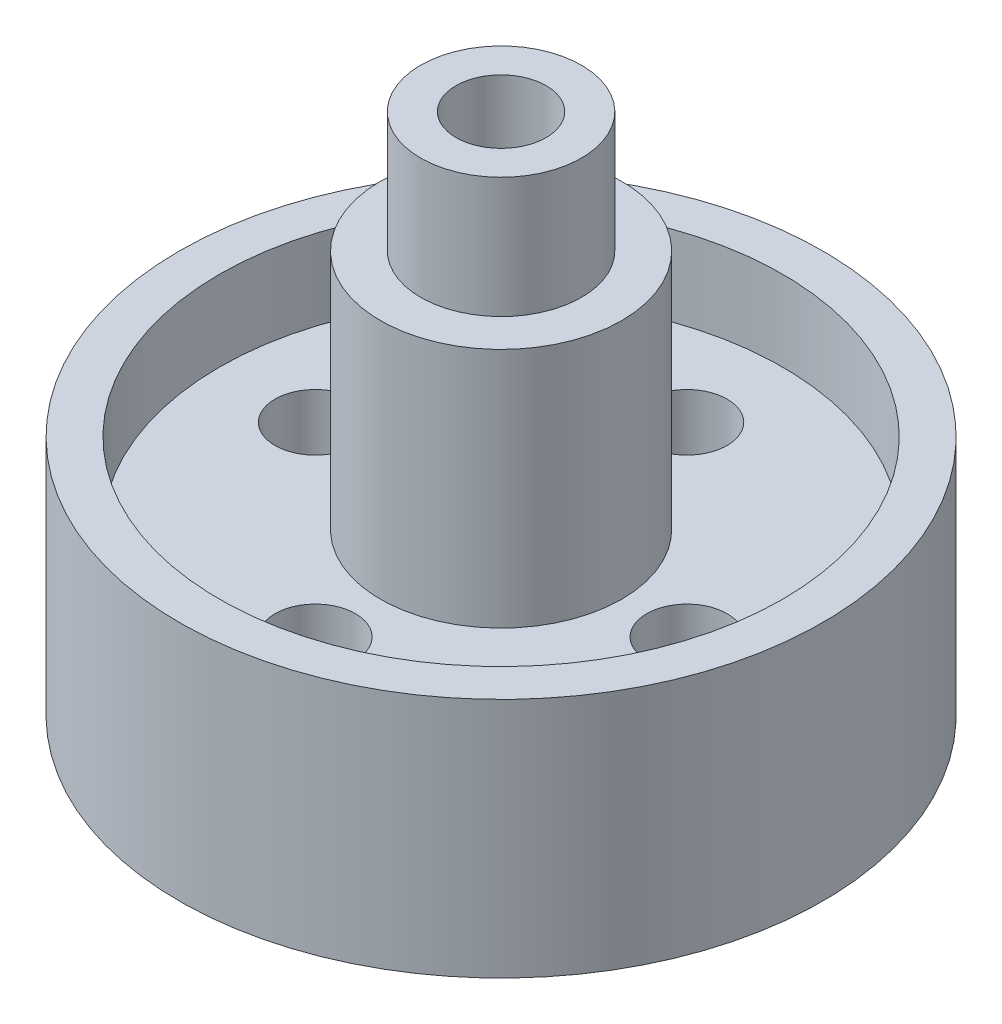
from build123d import *

# Parameters (mm, degrees)
SKETCH1_W           = 50.8
SKETCH1_H           = 25.4
SKETCH2_R           = 6.35
CUT_EXTRUDE1_DEPTH  = 26.4
SKETCH4_R           = 50.8
SKETCH4_R_2         = 44.45
BOSS_EXTRUDE1_DEPTH = 12.7
SKETCH6_R           = 19.05
BOSS_EXTRUDE2_DEPTH = 38.1
SKETCH7_R           = 12.7
BOSS_EXTRUDE3_DEPTH = 19.05
SKETCH8_R           = 7.112
CUT_EXTRUDE2_DEPTH  = 83.55


with BuildPart() as part:
    # Sketch1 → Revolve1 (revolve)
    with BuildSketch(Plane.XY):
        with Locations((25.4, 12.7)):
            Rectangle(SKETCH1_W, SKETCH1_H)
    revolve(axis=Axis((0, 25.4, 0), (0, -1, 0)))

    # Sketch2 → Cut-Extrude1 (cut, through all)
    with BuildSketch(Plane(origin=(0, 25.4, 0), x_dir=(1, 0, 0), z_dir=(0, 1, 0))):
        with Locations((29.337, 0)):
            Circle(SKETCH2_R)
        with Locations((0, -29.337)):
            Circle(SKETCH2_R)
        with Locations((-29.337, 0)):
            Circle(SKETCH2_R)
        with Locations((0, 29.337)):
            Circle(SKETCH2_R)
    extrude(amount=-CUT_EXTRUDE1_DEPTH, mode=Mode.SUBTRACT)

    # Sketch4 → Boss-Extrude1 (add)
    with BuildSketch(Plane(origin=(0, 25.4, 0), x_dir=(1, 0, 0), z_dir=(0, 1, 0))):
        Circle(SKETCH4_R)
        Circle(SKETCH4_R_2, mode=Mode.SUBTRACT)
    extrude(amount=BOSS_EXTRUDE1_DEPTH)

    # Sketch6 → Boss-Extrude2 (add)
    with BuildSketch(Plane(origin=(0, 25.4, 0), x_dir=(1, 0, 0), z_dir=(0, 1, 0))):
        Circle(SKETCH6_R)
    extrude(amount=BOSS_EXTRUDE2_DEPTH)

    # Sketch7 → Boss-Extrude3 (add)
    with BuildSketch(Plane(origin=(0, 63.5, 0), x_dir=(1, 0, 0), z_dir=(0, 1, 0))):
        Circle(SKETCH7_R)
    extrude(amount=BOSS_EXTRUDE3_DEPTH)

    # Sketch8 → Cut-Extrude2 (cut, through all)
    with BuildSketch(Plane(origin=(0, 82.55, 0), x_dir=(1, 0, 0), z_dir=(0, 1, 0))):
        Circle(SKETCH8_R)
    extrude(amount=-CUT_EXTRUDE2_DEPTH, mode=Mode.SUBTRACT)


solid = part.part
